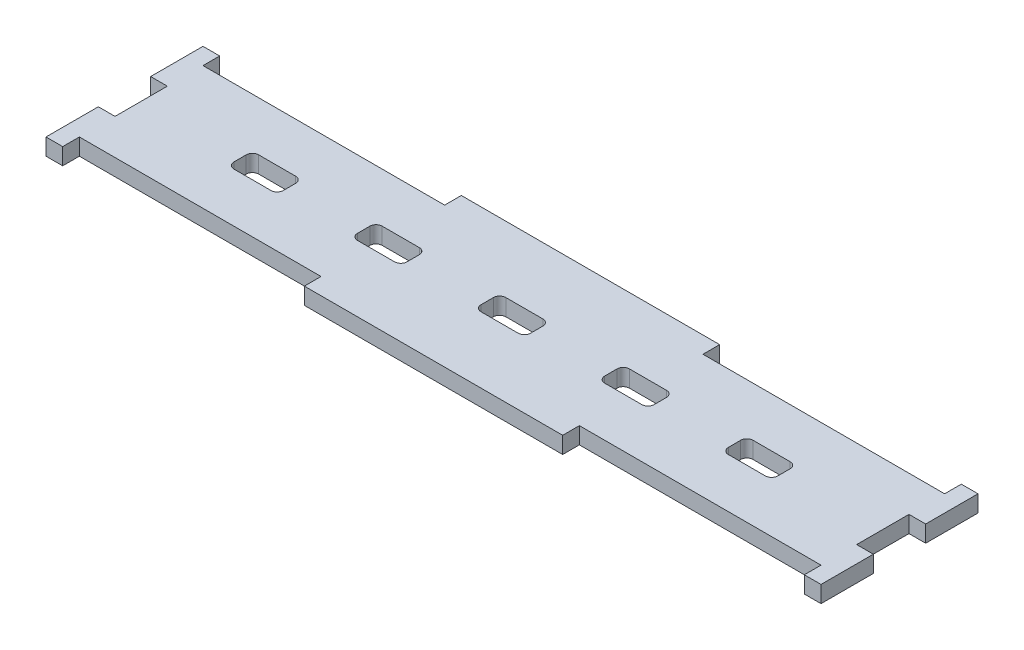
from build123d import *

# Parameters (mm, degrees)
BOSS_EXTRUDE1_DEPTH = 2.7


with BuildPart() as part:
    # Sketch1 → Boss-Extrude1 (new body)
    with BuildSketch(Plane(origin=(0, 0, 0), x_dir=(1, 0, 0), z_dir=(0, 1, 0))):
        Polygon((-62.7, 12.7), (-60, 12.7), (-60, 10), (-20.9, 10), (-20.9, 12.7), (20.9, 12.7), (20.9, 10), (60, 10), (60, 12.7), (62.7, 12.7), (62.7, 4.233333333), (60, 4.233333333), (60, -4.233333333), (62.7, -4.233333333), (62.7, -12.7), (60, -12.7), (60, -10), (20.9, -10), (20.9, -12.7), (-20.9, -12.7), (-20.9, -10), (-60, -10), (-60, -12.7), (-62.7, -12.7), (-62.7, -4.233333333), (-60, -4.233333333), (-60, 4.233333333), (-62.7, 4.233333333), align=None)
        with BuildLine():
            Line((-37, 2), (-43, 2))
            ThreePointArc((-43, 2), (-43.707106781, 1.707106781), (-44, 1))
            Line((-44, 1), (-44, -1))
            ThreePointArc((-44, -1), (-43.707106781, -1.707106781), (-43, -2))
            Line((-43, -2), (-37, -2))
            ThreePointArc((-37, -2), (-36.292893219, -1.707106781), (-36, -1))
            Line((-36, -1), (-36, 1))
            ThreePointArc((-36, 1), (-36.292893219, 1.707106781), (-37, 2))
        make_face(mode=Mode.SUBTRACT)
        with BuildLine():
            Line((-23, 2), (-17, 2))
            ThreePointArc((-17, 2), (-16.292893219, 1.707106781), (-16, 1))
            Line((-16, 1), (-16, -1))
            ThreePointArc((-16, -1), (-16.292893219, -1.707106781), (-17, -2))
            Line((-17, -2), (-23, -2))
            ThreePointArc((-23, -2), (-23.707106781, -1.707106781), (-24, -1))
            Line((-24, -1), (-24, 1))
            ThreePointArc((-24, 1), (-23.707106781, 1.707106781), (-23, 2))
        make_face(mode=Mode.SUBTRACT)
        with BuildLine():
            Line((-3, 2), (3, 2))
            ThreePointArc((3, 2), (3.707106781, 1.707106781), (4, 1))
            Line((4, 1), (4, -1))
            ThreePointArc((4, -1), (3.707106781, -1.707106781), (3, -2))
            Line((3, -2), (-3, -2))
            ThreePointArc((-3, -2), (-3.707106781, -1.707106781), (-4, -1))
            Line((-4, -1), (-4, 1))
            ThreePointArc((-4, 1), (-3.707106781, 1.707106781), (-3, 2))
        make_face(mode=Mode.SUBTRACT)
        with BuildLine():
            Line((17, 2), (23, 2))
            ThreePointArc((23, 2), (23.707106781, 1.707106781), (24, 1))
            Line((24, 1), (24, -1))
            ThreePointArc((24, -1), (23.707106781, -1.707106781), (23, -2))
            Line((23, -2), (17, -2))
            ThreePointArc((17, -2), (16.292893219, -1.707106781), (16, -1))
            Line((16, -1), (16, 1))
            ThreePointArc((16, 1), (16.292893219, 1.707106781), (17, 2))
        make_face(mode=Mode.SUBTRACT)
        with BuildLine():
            Line((37, 2), (43, 2))
            ThreePointArc((43, 2), (43.707106781, 1.707106781), (44, 1))
            Line((44, 1), (44, -1))
            ThreePointArc((44, -1), (43.707106781, -1.707106781), (43, -2))
            Line((43, -2), (37, -2))
            ThreePointArc((37, -2), (36.292893219, -1.707106781), (36, -1))
            Line((36, -1), (36, 1))
            ThreePointArc((36, 1), (36.292893219, 1.707106781), (37, 2))
        make_face(mode=Mode.SUBTRACT)
    extrude(amount=BOSS_EXTRUDE1_DEPTH)


solid = part.part
